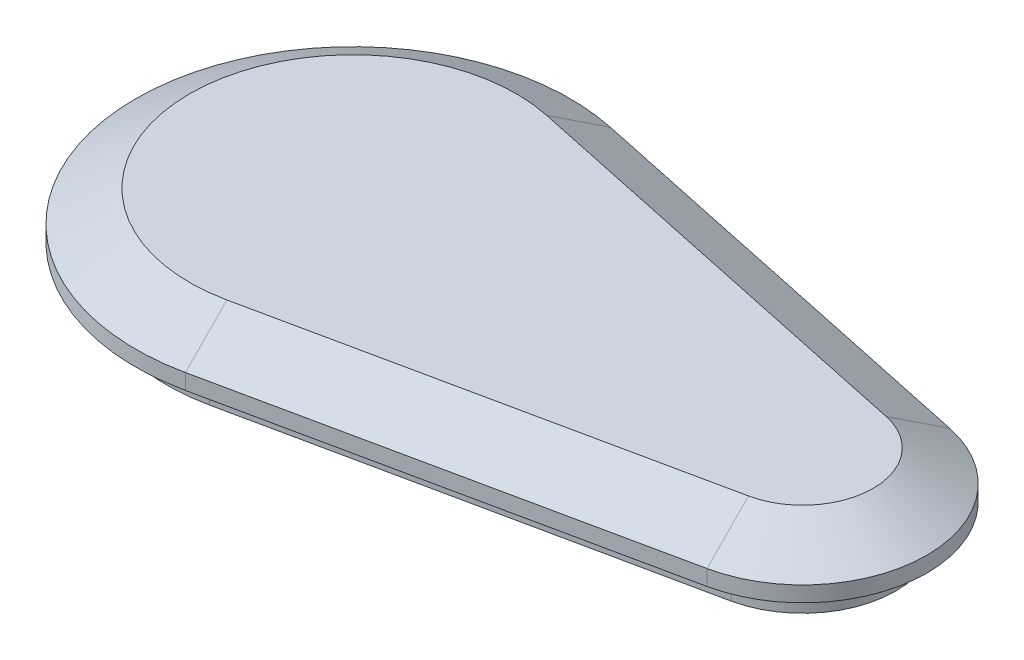
from build123d import *

# Parameters (mm, degrees)
BOSS_EXTRUDE1_DEPTH = 2
BOSS_EXTRUDE2_DEPTH = 1
BOSS_EXTRUDE3_DEPTH = 2
BOSS_EXTRUDE3_TAPER = 60


with BuildPart() as part:
    # Sketch1 → Boss-Extrude1 (new body)
    with BuildSketch(Plane(origin=(0, 0, 0), x_dir=(1, 0, 0), z_dir=(0, 1, 0))):
        with BuildLine():
            Line((2.482758621, 11.740353897), (30.24137931, 5.870176949))
            ThreePointArc((30.24137931, 5.870176949), (35, 0), (30.24137931, -5.870176949))
            Line((30.24137931, -5.870176949), (2.482758621, -11.740353897))
            ThreePointArc((2.482758621, -11.740353897), (-12, 0), (2.482758621, 11.740353897))
        make_face()
    extrude(amount=BOSS_EXTRUDE1_DEPTH)

    # Sketch2 → Boss-Extrude2 (add)
    with BuildSketch(Plane(origin=(0, 2, 0), x_dir=(1, 0, 0), z_dir=(0, 1, 0))):
        with BuildLine():
            Line((30.655172414, 7.826902598), (2.896551724, 13.697079547))
            ThreePointArc((2.896551724, 13.697079547), (-14, 0), (2.896551724, -13.697079547))
            Line((2.896551724, -13.697079547), (30.655172414, -7.826902598))
            ThreePointArc((30.655172414, -7.826902598), (37, 0), (30.655172414, 7.826902598))
        make_face()
    extrude(amount=BOSS_EXTRUDE2_DEPTH)

    # Sketch3 → Boss-Extrude3 (add)
    with BuildSketch(Plane(origin=(0, 3, 0), x_dir=(1, 0, 0), z_dir=(0, 1, 0))):
        with BuildLine():
            Line((30.655172414, 7.826902598), (2.896551724, 13.697079547))
            ThreePointArc((2.896551724, 13.697079547), (-14, 0), (2.896551724, -13.697079547))
            Line((2.896551724, -13.697079547), (30.655172414, -7.826902598))
            ThreePointArc((30.655172414, -7.826902598), (37, 0), (30.655172414, 7.826902598))
        make_face()
    extrude(amount=BOSS_EXTRUDE3_DEPTH, taper=BOSS_EXTRUDE3_TAPER)


solid = part.part
